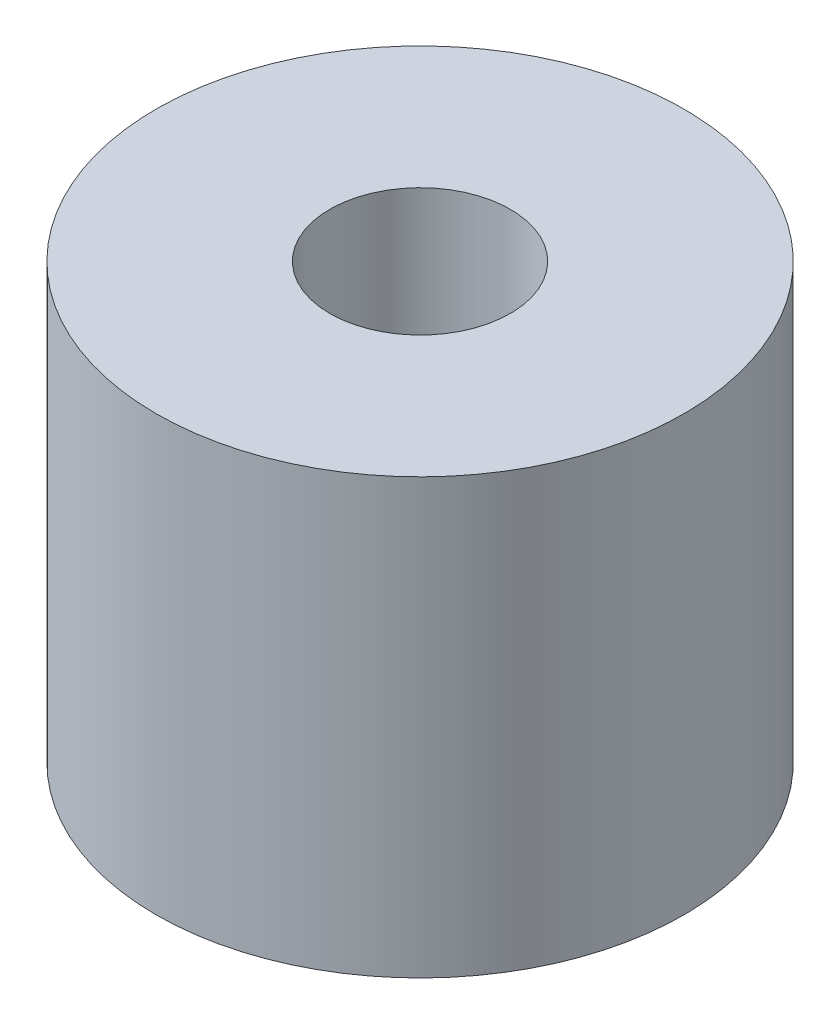
from build123d import *

# Parameters (mm, degrees)
SKETCH1_R           = 7.6
SKETCH1_R_2         = 2.6
BOSS_EXTRUDE1_DEPTH = 12.5


with BuildPart() as part:
    # Sketch1 → Boss-Extrude1 (new body)
    with BuildSketch(Plane(origin=(0, 0, 0), x_dir=(1, 0, 0), z_dir=(0, 1, 0))):
        Circle(SKETCH1_R)
        Circle(SKETCH1_R_2, mode=Mode.SUBTRACT)
    extrude(amount=BOSS_EXTRUDE1_DEPTH)


solid = part.part
